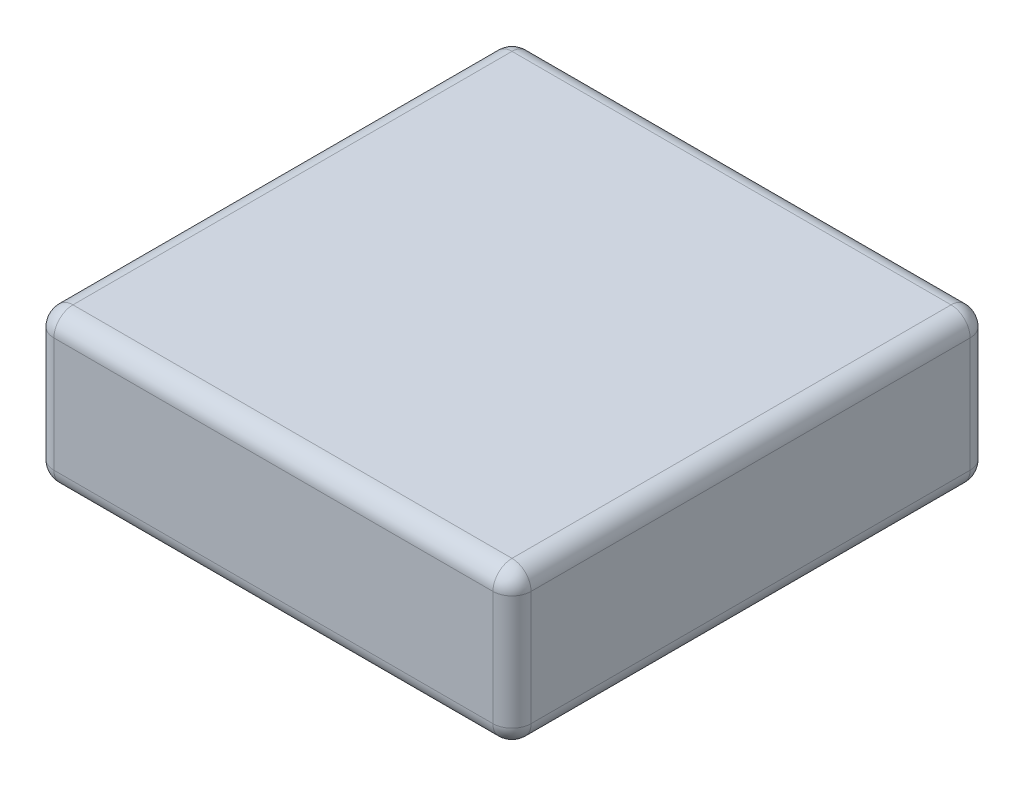
from build123d import *

# Parameters (mm, degrees)
SKETCH1_W  = 25
SKETCH1_H  = 25
BASE_DEPTH = 8
FILLET1_R  = 1


with BuildPart() as part:
    # Sketch1 → Base (new body)
    with BuildSketch(Plane(origin=(0, 0, 0), x_dir=(1, 0, 0), z_dir=(0, 1, 0))):
        Rectangle(SKETCH1_W, SKETCH1_H)
    extrude(amount=BASE_DEPTH)

    # Fillet1
    fillet1_edges = [part.edges().sort_by_distance(p)[0] for p in [
        (12.5, 8, 0),
        (0, 8, -12.5),
        (-12.5, 8, 0),
        (0, 0, -12.5),
        (12.5, 0, 0),
        (0, 0, 12.5),
        (-12.5, 0, 0),
        (-12.5, 4, -12.5),
        (12.5, 4, -12.5),
        (12.5, 4, 12.5),
        (-12.5, 4, 12.5),
        (0, 8, 12.5),
    ]]
    fillet(fillet1_edges, radius=FILLET1_R)


solid = part.part
